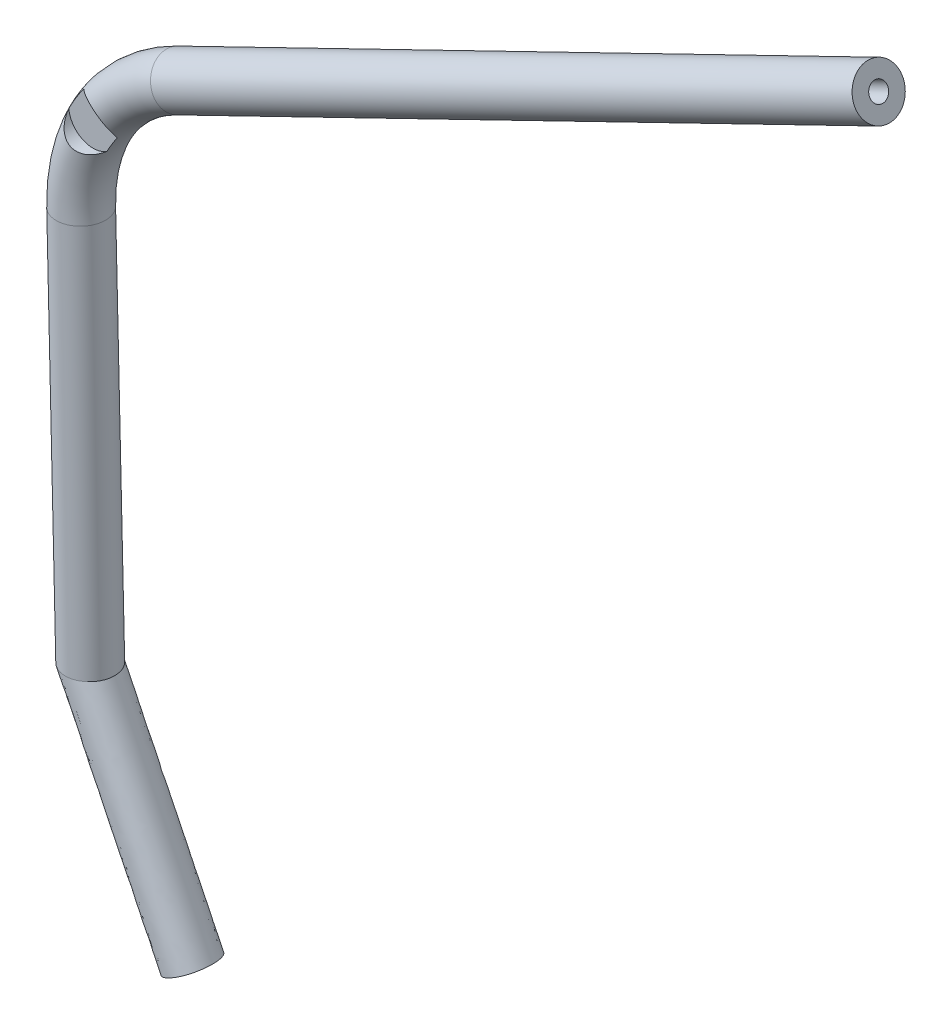
from build123d import *

# Parameters (mm, degrees)
SKETCH5_R               = 12.7
SKETCH5_R_2             = 4.7625
SKETCH6_R               = 12.7
SKETCH6_R_2             = 4.7625
BOSS_EXTRUDE3_DEPTH     = 406.4
SKETCH7_R               = 12.7
SKETCH7_R_2             = 4.7625
BOSS_EXTRUDE4_DEPTH     = 203.2
SKETCH8_R               = 12.7
CUT_EXTRUDE1_DEPTH      = 6.35
SKETCH9_R               = 12.7
SKETCH9_R_2             = 4.7625
CUT_EXTRUDE2_DEPTH      = 462.222817168
CUT_EXTRUDE2_DEPTH_BACK = 462.222817168


with BuildPart() as part:
    # Sweep1: sweep along a path in Sketch4
    with BuildLine(Plane.XY) as sweep1_path:
        ThreePointArc((-38.874671546, 79.949796199), (-75.907697444, 46.273442371), (-88.87582946, -2.072905643))
    # Sketch5 → Sweep1 (sweep)
    with BuildSketch(Plane(origin=(0, 0, 0), x_dir=(1, 0, 0), z_dir=(0, 1, 0))):
        with Locations((-88.87582946, 0)):
            Circle(SKETCH5_R)
        with Locations((-88.87582946, 0)):
            Circle(SKETCH5_R_2, mode=Mode.SUBTRACT)
    sweep(path=sweep1_path.line)

    # Sketch6 → Boss-Extrude3 (add)
    with BuildSketch(Plane(origin=(0, 0, 0), x_dir=(0, 0, -1), z_dir=(0.8993227918843839, 0.43728539421901275, 0))):
        with Locations(Location((0, 88.87582946, 0), (0, 0, 180))):
            Circle(SKETCH6_R)
        with Locations(Location((0, 88.87582946, 0), (0, 0, 180))):
            Circle(SKETCH6_R_2, mode=Mode.SUBTRACT)
    extrude(amount=BOSS_EXTRUDE3_DEPTH)

    # Sketch7 → Boss-Extrude4 (add)
    with BuildSketch(Plane(origin=(0, 0, 0), x_dir=(-0.9997281154099812, -0.023317273828803834, 0), z_dir=(0.023317273828803834, -0.9997281154099812, 0))):
        with Locations((88.87582946, 0)):
            Circle(SKETCH7_R)
        with Locations((88.87582946, 0)):
            Circle(SKETCH7_R_2, mode=Mode.SUBTRACT)
    extrude(amount=BOSS_EXTRUDE4_DEPTH)

    # Sketch8 → Cut-Extrude1 (cut)
    with BuildSketch(Plane.XY.offset(12.7)):
        with Locations((-76.269889492, 46.494235168)):
            Circle(SKETCH8_R)
    extrude(amount=-CUT_EXTRUDE1_DEPTH, mode=Mode.SUBTRACT)

    # Sweep2: sweep along a path in Sketch11
    with BuildLine(Plane.XY) as sweep2_path:
        Line((-84.113595449, -205.217095104), (-28.578350384, -319.431089673))
    # Sketch9 → Sweep2 (sweep)
    with BuildSketch(Plane(origin=(4.738070042, -203.144753051, 0), x_dir=(-0.9997281154099812, -0.023317273828803834, 0), z_dir=(0.023317273828803834, -0.9997281154099812, 0))):
        with Locations((88.87582946, 0)):
            Circle(SKETCH9_R)
        with Locations((88.87582946, 0)):
            Circle(SKETCH9_R_2, mode=Mode.SUBTRACT)
    sweep(path=sweep2_path.line)

    # Sketch16 → Cut-Extrude2 (cut, two sides)
    with BuildSketch(Plane.XY) as cut_extrude2_sk:
        Polygon((-41.274897449, -319.727219051), (-20.504520989, -309.627861689), (-15.881803318, -319.134960295), align=None)
    extrude(amount=CUT_EXTRUDE2_DEPTH, mode=Mode.SUBTRACT)
    extrude(cut_extrude2_sk.sketch, amount=-CUT_EXTRUDE2_DEPTH_BACK, mode=Mode.SUBTRACT)


solid = part.part
